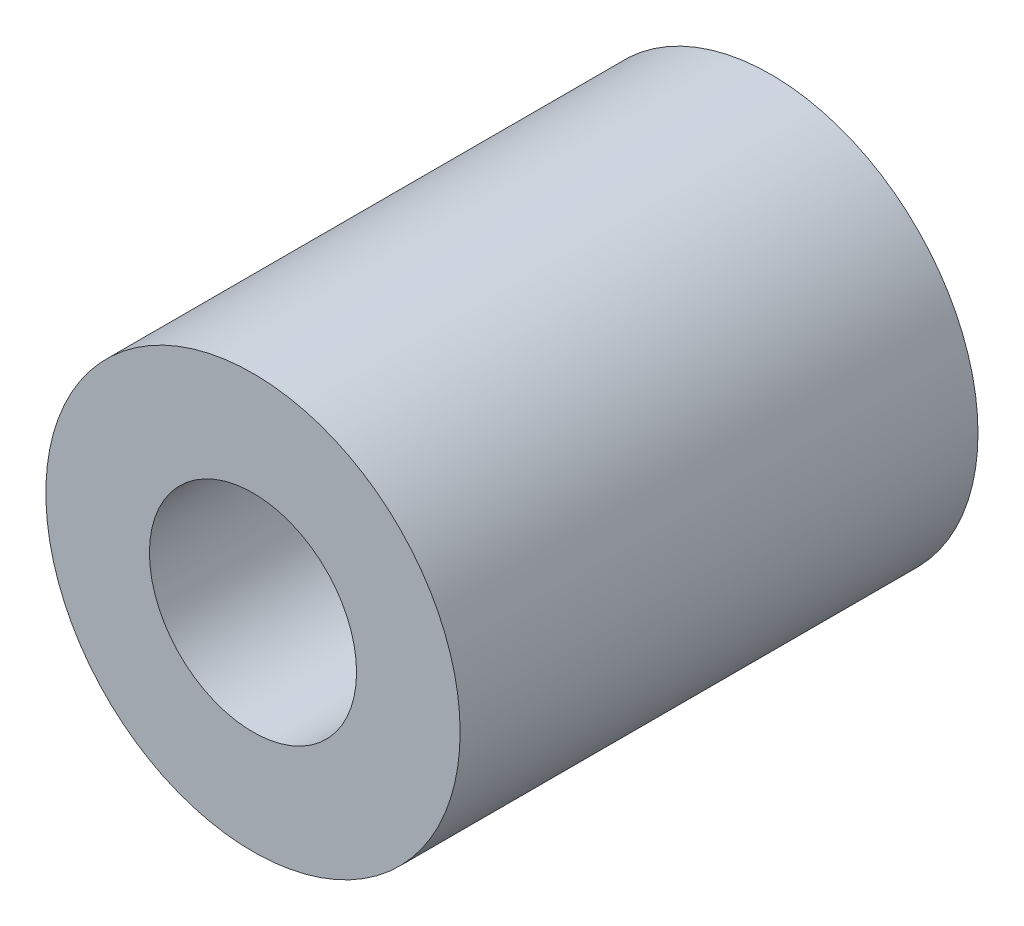
from build123d import *

# Parameters (mm, degrees)
SKETCH1_R           = 10
BOSS_EXTRUDE1_DEPTH = 12.5
SKETCH2_R           = 5
CUT_EXTRUDE2_DEPTH  = 8


with BuildPart() as part:
    # Sketch1 → Boss-Extrude1 (new body, symmetric)
    with BuildSketch(Plane.XY):
        Circle(SKETCH1_R)
    extrude(amount=BOSS_EXTRUDE1_DEPTH, both=True)

    # Sketch2 → Cut-Extrude2 (cut)
    with BuildSketch(Plane.XY.offset(12.5)):
        Circle(SKETCH2_R)
    cut_extrude2 = extrude(amount=-CUT_EXTRUDE2_DEPTH, mode=Mode.SUBTRACT)

    # Mirror1: Cut-Extrude2 across plane
    add(cut_extrude2.mirror(Plane.XY), mode=Mode.SUBTRACT)


solid = part.part
